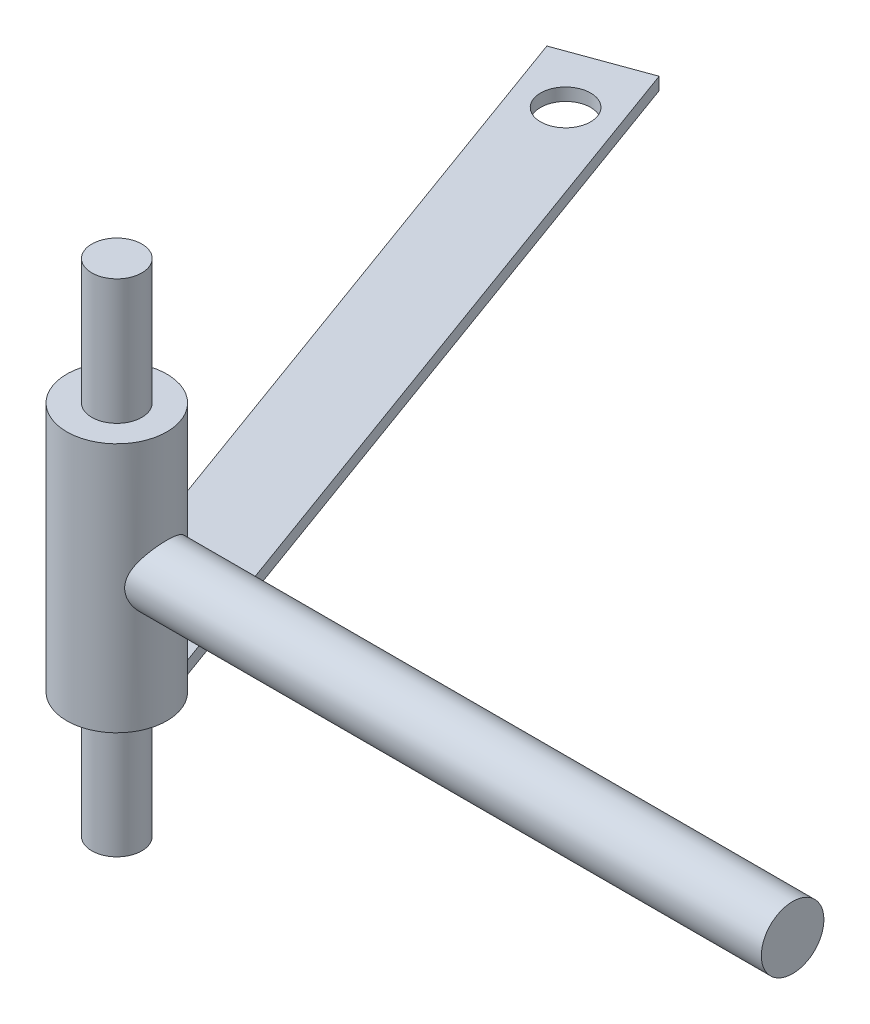
from build123d import *

# Parameters (mm, degrees)
SKETCH1_R           = 4
BOSS_EXTRUDE1_DEPTH = 40
SKETCH3_R           = 8
BOSS_EXTRUDE2_DEPTH = 20
SKETCH4_R           = 5
BOSS_EXTRUDE3_DEPTH = 108
SKETCH5_W           = 14
SKETCH5_H           = 2
BOSS_EXTRUDE4_DEPTH = 130
CUT_EXTRUDE1_REACH  = 26
SKETCH6_R           = 4


with BuildPart() as part:
    # Sketch1 → Boss-Extrude1 (new body, symmetric)
    with BuildSketch(Plane(origin=(0, 0, 0), x_dir=(1, 0, 0), z_dir=(0, 1, 0))):
        Circle(SKETCH1_R)
    extrude(amount=BOSS_EXTRUDE1_DEPTH, both=True)

    # Sketch3 → Boss-Extrude2 (add, symmetric)
    with BuildSketch(Plane(origin=(0, 0, 0), x_dir=(1, 0, 0), z_dir=(0, 1, 0))):
        Circle(SKETCH3_R)
    extrude(amount=BOSS_EXTRUDE2_DEPTH, both=True)

    # Sketch4 → Boss-Extrude3 (add)
    with BuildSketch(Plane(origin=(0, 0, 0), x_dir=(0, 0, -1), z_dir=(1, 0, 0))):
        Circle(SKETCH4_R)
    extrude(amount=BOSS_EXTRUDE3_DEPTH)

    # Sketch5 → Boss-Extrude4 (add)
    with BuildSketch(Plane(origin=(0, 0, 0), x_dir=(0.939692621, 0, -0.342020143), z_dir=(0.342020143, 0, 0.939692621))):
        with Locations((0, -17)):
            Rectangle(SKETCH5_W, SKETCH5_H)
    extrude(amount=-BOSS_EXTRUDE4_DEPTH)

    # Sketch6 → Cut-Extrude1 (cut, up to next)
    with BuildSketch(Plane(origin=(0, -16, 0), x_dir=(1, 0, 0), z_dir=(0, 1, 0)), mode=Mode.PRIVATE) as cut_extrude1_sk1:
        with Locations((-41.042417199, 112.763114494)):
            Circle(SKETCH6_R)
    cut_extrude1_tool1 = extrude(cut_extrude1_sk1.sketch, amount=-CUT_EXTRUDE1_REACH, mode=Mode.PRIVATE) & part.part
    add(cut_extrude1_tool1.solids().sort_by_distance((-41.042417, -16, -112.763114))[0], mode=Mode.SUBTRACT)


solid = part.part
